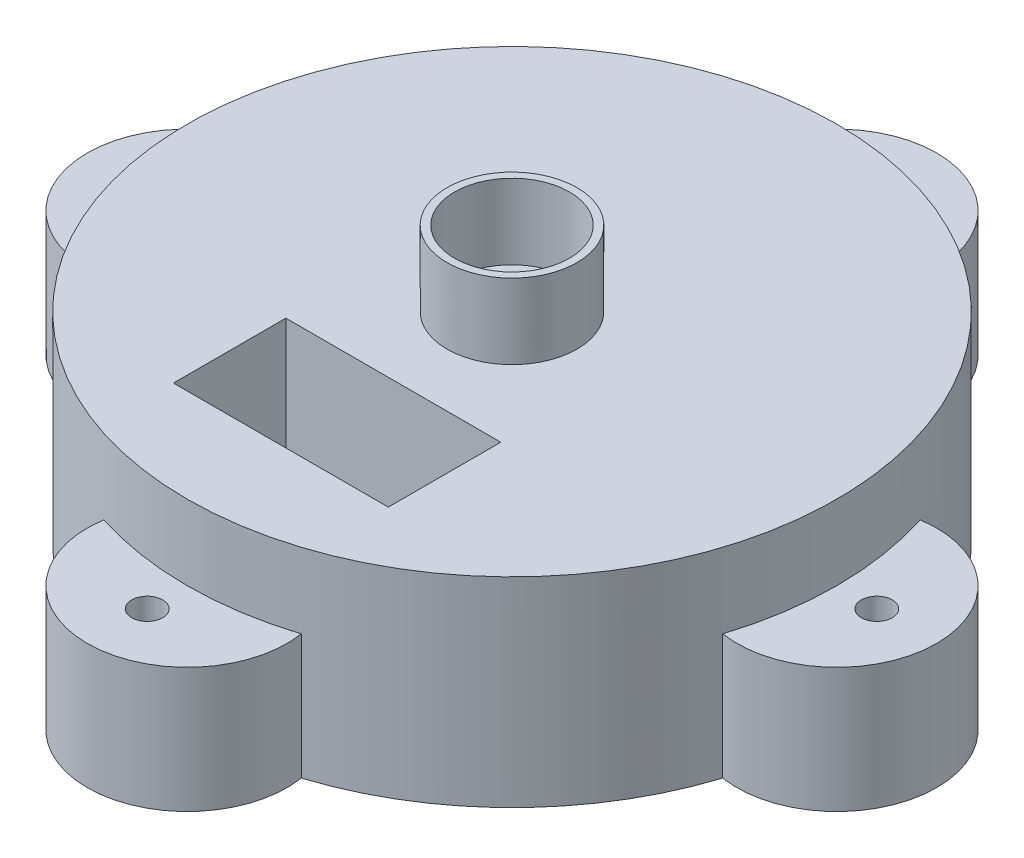
from build123d import *

# Parameters (mm, degrees)
SKETCH2_R           = 65
BOSS_EXTRUDE1_DEPTH = 40
SKETCH4_W           = 43
SKETCH4_H           = 22.5
CUT_EXTRUDE1_DEPTH  = 38
SKETCH6_R           = 3.1
BOSS_EXTRUDE2_DEPTH = 25
SKETCH9_R           = 13
SKETCH9_R_2         = 11.5
BOSS_EXTRUDE3_DEPTH = 15
SKETCH5_W           = 15
SKETCH5_H           = 5
CUT_EXTRUDE2_DEPTH  = 60


with BuildPart() as part:
    # Sketch2 → Boss-Extrude1 (new body)
    with BuildSketch(Plane(origin=(0, 0, 0), x_dir=(1, 0, 0), z_dir=(0, 1, 0))):
        Circle(SKETCH2_R)
    extrude(amount=BOSS_EXTRUDE1_DEPTH)

    # Sketch4 → Cut-Extrude1 (cut)
    with BuildSketch(Plane.XZ.offset(-40)):
        with Locations((0, 35)):
            Rectangle(SKETCH4_W, SKETCH4_H)
    extrude(amount=CUT_EXTRUDE1_DEPTH, mode=Mode.SUBTRACT)

    # Sketch6 → Boss-Extrude2 (add)
    with BuildSketch(Plane(origin=(0, 0, 0), x_dir=(1, 0, 0), z_dir=(0, 1, 0))):
        with BuildLine():
            ThreePointArc((-61.923102255, -19.761816899), (-65, 8.332e-05), (-61.923051591, 19.761975651))
            ThreePointArc((-61.923051591, 19.761975651), (-85, 0.000108957), (-61.923102255, -19.761816899))
        make_face()
        with Locations((-73, 8.332e-05)):
            Circle(SKETCH6_R, mode=Mode.SUBTRACT)
        with BuildLine():
            ThreePointArc((19.761975651, 61.923051591), (0.000108957, 85), (-19.761816899, 61.923102255))
            ThreePointArc((-19.761816899, 61.923102255), (8.332e-05, 65), (19.761975651, 61.923051591))
        make_face()
        with Locations((8.332e-05, 73)):
            Circle(SKETCH6_R, mode=Mode.SUBTRACT)
        with BuildLine():
            ThreePointArc((19.761816899, -61.923102255), (-8.332e-05, -65), (-19.761975651, -61.923051591))
            ThreePointArc((-19.761975651, -61.923051591), (-0.000108957, -85), (19.761816899, -61.923102255))
        make_face()
        with Locations((-8.332e-05, -73)):
            Circle(SKETCH6_R, mode=Mode.SUBTRACT)
        with BuildLine():
            ThreePointArc((61.923051591, -19.761975651), (85, -0.000108957), (61.923102255, 19.761816899))
            ThreePointArc((61.923102255, 19.761816899), (65, -8.332e-05), (61.923051591, -19.761975651))
        make_face()
        with Locations((73, -8.332e-05)):
            Circle(SKETCH6_R, mode=Mode.SUBTRACT)
    extrude(amount=BOSS_EXTRUDE2_DEPTH)

    # Sketch9 → Boss-Extrude3 (add)
    with BuildSketch(Plane(origin=(0, 40, 0), x_dir=(-1, 0, 0), z_dir=(0, -1, 0))):
        Circle(SKETCH9_R)
        Circle(SKETCH9_R_2, mode=Mode.SUBTRACT)
    extrude(amount=-BOSS_EXTRUDE3_DEPTH)

    # Sketch5 → Cut-Extrude2 (cut)
    with BuildSketch(Plane(origin=(-21.5, 0, 62.75), x_dir=(0, 0, 1), z_dir=(-1, 0, 0))):
        with Locations((-26.716652448, 9.82604923)):
            Rectangle(SKETCH5_W, SKETCH5_H)
    extrude(amount=CUT_EXTRUDE2_DEPTH, mode=Mode.SUBTRACT)


solid = part.part
